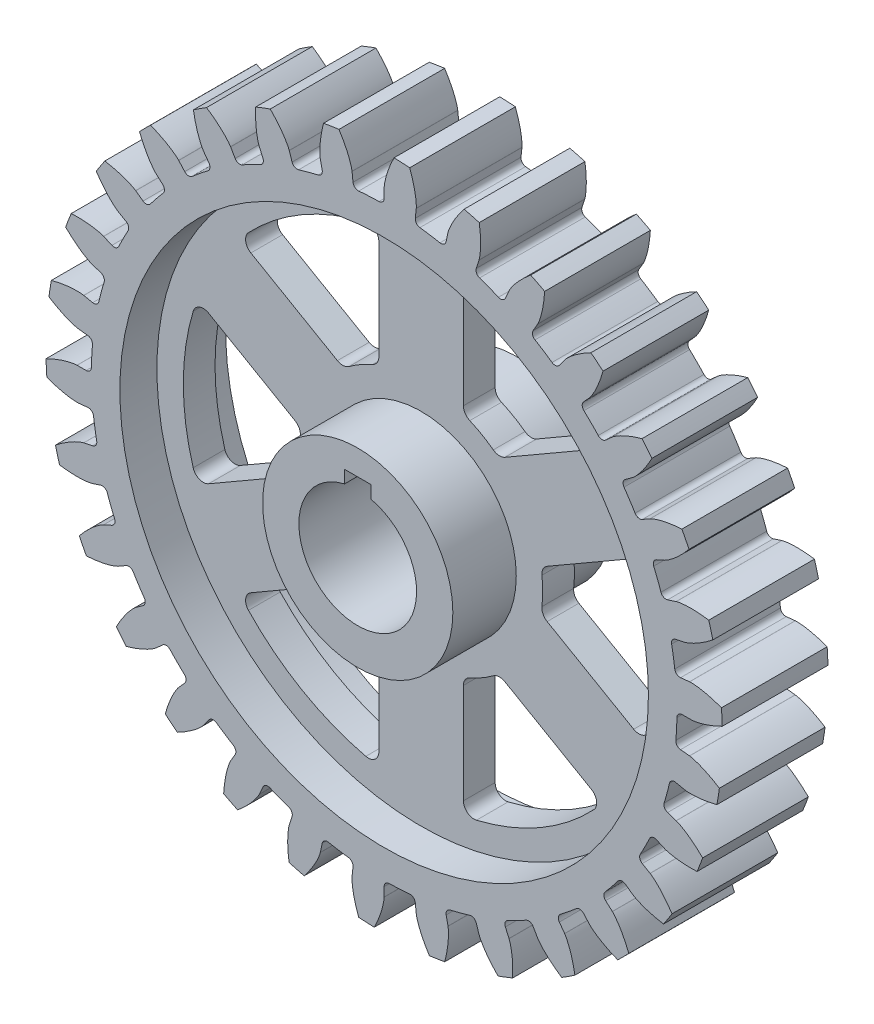
from build123d import *

# Parameters (mm, degrees)
BOSS_EXTRUDE1_START       = -12.7
BOSS_EXTRUDE1_DEPTH       = 25.4
FILLET5_R                 = 1.27
FILLET6_R                 = 1.27
CIRPATTERN2_COUNT         = 30
FILLET5_OF_CIRPATTERN2_R  = 1.27
FILLET6_OF_CIRPATTERN2_R  = 1.27
CUT_EXTRUDE2_DEPTH        = 20.05
CUT_EXTRUDE2_DEPTH_BACK   = 20.05
CUT_EXTRUDE3_DEPTH        = 20.05
FILLET7_R                 = 2.54
FILLET8_R                 = 2.54
FILLET9_R                 = 2.54
FILLET10_R                = 2.54
CIRPATTERN3_COUNT         = 6
FILLET7_OF_CIRPATTERN3_R  = 2.54
FILLET8_OF_CIRPATTERN3_R  = 2.54
FILLET9_OF_CIRPATTERN3_R  = 2.54
FILLET10_OF_CIRPATTERN3_R = 2.54


with BuildPart() as part:
    # Sketch1 → Revolve1 (revolve)
    with BuildSketch(Plane(origin=(0, 0, 0), x_dir=(0, 0, -1), z_dir=(1, 0, 0))):
        Polygon((-19.05, 0), (19.05, 0), (19.05, 22.86), (3.81, 22.86), (3.81, 63.5), (12.7, 63.5), (12.7, 70.358), (-12.7, 70.358), (-12.7, 63.5), (-3.81, 63.5), (-3.81, 22.86), (-19.05, 22.86), align=None)
    revolve(axis=Axis((0, 0, 20.955), (0, 0, -1)))

    # Sketch2 → Boss-Extrude1 (add)
    with BuildSketch(Plane.XY.offset(BOSS_EXTRUDE1_START)):
        with BuildLine():
            Line((73.787, 0), (70.358, 0))
            ThreePointArc((70.358, 0), (70.261576806, 3.682253209), (69.972571514, 7.354413619))
            Line((69.972571514, 7.354413619), (73.382787093, 7.712841719))
            add(Edge.make_bspline(
                [(73.382787093, 7.712841719), (73.43715987, 7.717395802), (73.589918341, 7.726601957), (73.879547725, 7.729925227), (74.35231969, 7.715277138), (74.954131213, 7.6672137), (75.72992196, 7.571305619), (76.639687317, 7.415196261), (77.633599645, 7.19844931), (78.70649498, 6.91461528), (79.695065382, 6.611264762), (80.410512864, 6.366046257), (80.860156706, 6.202224664), (81.04836389, 6.131974458)],
                knots=[0, 0, 0, 0, 0, 0.005376748, 0.015083688, 0.02853182, 0.046610139, 0.064854849, 0.092110525, 0.119476175, 0.146842495, 0.174208853, 0.194009379, 0.194009379, 0.194009379, 0.194009379, 0.194009379], degree=4))
            ThreePointArc((81.04836389, 6.131974458), (81.168608585, 4.253866523), (81.245338339, 2.373478068))
            add(Edge.make_bspline(
                [(73.787, 0), (73.841550948, 0.001154368), (73.994434897, 0.007966253), (74.282825037, 0.034935703), (74.751475967, 0.098921675), (75.344966706, 0.20962825), (76.106482465, 0.386103151), (76.994946161, 0.6364537), (77.960757507, 0.955905417), (78.998106674, 1.350332676), (79.949552821, 1.755355153), (80.635448694, 2.074014951), (81.06550532, 2.283939691), (81.245338339, 2.373478068)],
                knots=[0, 0, 0, 0, 0, 0.005376748, 0.015083688, 0.02853182, 0.046610139, 0.064854849, 0.092110525, 0.119476175, 0.146842495, 0.174208853, 0.194009379, 0.194009379, 0.194009379, 0.194009379, 0.194009379], degree=4))
        make_face()
    boss_extrude1 = extrude(amount=BOSS_EXTRUDE1_DEPTH)

    # Fillet5
    fillet5_edges = [part.edges().sort_by_distance(p)[0] for p in [
        (73.382787093, 7.712841719, 0),
        (69.972571514, 7.354413619, 0),
    ]]
    fillet(fillet5_edges, radius=FILLET5_R)

    # Fillet6
    fillet6_edges = [part.edges().sort_by_distance(p)[0] for p in [
        (70.358, 0, 0),
        (73.787, 0, 0),
    ]]
    fillet(fillet6_edges, radius=FILLET6_R)

    # CirPattern2: Boss-Extrude1 ×30 about axis
    cirpattern2_axis = Axis((0, 0, 20.955), (0, 0, -1))
    for i in range(1, CIRPATTERN2_COUNT):
        add(boss_extrude1.rotate(cirpattern2_axis, i * 360 / CIRPATTERN2_COUNT))

    # Fillet5 of CirPattern2
    fillet5_of_cirpattern2_edges = [part.edges().sort_by_distance(p)[0] for p in [
        (73.382787093, -7.712841719, 0),
        (69.972571514, -7.354413619, 0),
        (70.175607168, -22.801436964, 0),
        (66.914434373, -21.74181769, 0),
        (63.901416469, -36.8935, 0),
        (60.931815359, -35.179, 0),
        (54.834427237, -49.373140051, 0),
        (52.286183631, -47.078691202, 0),
        (43.370910411, -59.694936964, 0),
        (41.355394781, -56.92081769, 0),
        (30.011876683, -67.407778683, 0),
        (28.617176734, -64.275231309, 0),
        (15.34117993, -72.174577015, 0),
        (14.628250743, -68.820508892, 0),
        (0, -73.787, 0),
        (0, -70.358, 0),
        (-15.34117993, -72.174577015, 0),
        (-14.628250743, -68.820508892, 0),
        (-30.011876683, -67.407778683, 0),
        (-28.617176734, -64.275231309, 0),
        (-43.370910411, -59.694936964, 0),
        (-41.355394781, -56.92081769, 0),
        (-54.834427237, -49.373140051, 0),
        (-52.286183631, -47.078691202, 0),
        (-63.901416469, -36.8935, 0),
        (-60.931815359, -35.179, 0),
        (-70.175607168, -22.801436964, 0),
        (-66.914434373, -21.74181769, 0),
        (-73.382787093, -7.712841719, 0),
        (-69.972571514, -7.354413619, 0),
        (-73.382787093, 7.712841719, 0),
        (-69.972571514, 7.354413619, 0),
        (-70.175607168, 22.801436964, 0),
        (-66.914434373, 21.74181769, 0),
        (-63.901416469, 36.8935, 0),
        (-60.931815359, 35.179, 0),
        (-54.834427237, 49.373140051, 0),
        (-52.286183631, 47.078691202, 0),
        (-43.370910411, 59.694936964, 0),
        (-41.355394781, 56.92081769, 0),
        (-30.011876683, 67.407778683, 0),
        (-28.617176734, 64.275231309, 0),
        (-15.34117993, 72.174577015, 0),
        (-14.628250743, 68.820508892, 0),
        (0, 73.787, 0),
        (0, 70.358, 0),
        (15.34117993, 72.174577015, 0),
        (14.628250743, 68.820508892, 0),
        (30.011876683, 67.407778683, 0),
        (28.617176734, 64.275231309, 0),
        (43.370910411, 59.694936964, 0),
        (41.355394781, 56.92081769, 0),
        (54.834427237, 49.373140051, 0),
        (52.286183631, 47.078691202, 0),
        (63.901416469, 36.8935, 0),
        (60.931815359, 35.179, 0),
        (70.175607168, 22.801436964, 0),
        (66.914434373, 21.74181769, 0),
    ]]
    fillet(fillet5_of_cirpattern2_edges, radius=FILLET5_OF_CIRPATTERN2_R)

    # Fillet6 of CirPattern2
    fillet6_of_cirpattern2_edges = [part.edges().sort_by_distance(p)[0] for p in [
        (68.820508892, -14.628250743, 0),
        (72.174577015, -15.34117993, 0),
        (64.275231309, -28.617176734, 0),
        (67.407778683, -30.011876683, 0),
        (56.92081769, -41.355394781, 0),
        (59.694936964, -43.370910411, 0),
        (47.078691202, -52.286183631, 0),
        (49.373140051, -54.834427238, 0),
        (35.179, -60.931815359, 0),
        (36.8935, -63.901416469, 0),
        (21.74181769, -66.914434373, 0),
        (22.801436964, -70.175607168, 0),
        (7.354413619, -69.972571514, 0),
        (7.712841719, -73.382787094, 0),
        (-7.354413619, -69.972571514, 0),
        (-7.712841719, -73.382787094, 0),
        (-21.74181769, -66.914434373, 0),
        (-22.801436964, -70.175607168, 0),
        (-35.179, -60.931815359, 0),
        (-36.8935, -63.901416469, 0),
        (-47.078691202, -52.286183631, 0),
        (-49.373140051, -54.834427238, 0),
        (-56.92081769, -41.355394781, 0),
        (-59.694936964, -43.370910411, 0),
        (-64.275231309, -28.617176734, 0),
        (-67.407778683, -30.011876683, 0),
        (-68.820508892, -14.628250743, 0),
        (-72.174577015, -15.34117993, 0),
        (-70.358, 0, 0),
        (-73.787, 0, 0),
        (-68.820508892, 14.628250743, 0),
        (-72.174577015, 15.34117993, 0),
        (-64.275231309, 28.617176734, 0),
        (-67.407778683, 30.011876683, 0),
        (-56.92081769, 41.355394781, 0),
        (-59.694936964, 43.370910411, 0),
        (-47.078691202, 52.286183631, 0),
        (-49.373140051, 54.834427238, 0),
        (-35.179, 60.931815359, 0),
        (-36.8935, 63.901416469, 0),
        (-21.74181769, 66.914434373, 0),
        (-22.801436964, 70.175607168, 0),
        (-7.354413619, 69.972571514, 0),
        (-7.712841719, 73.382787094, 0),
        (7.354413619, 69.972571514, 0),
        (7.712841719, 73.382787094, 0),
        (21.74181769, 66.914434373, 0),
        (22.801436964, 70.175607168, 0),
        (35.179, 60.931815359, 0),
        (36.8935, 63.901416469, 0),
        (47.078691202, 52.286183631, 0),
        (49.373140051, 54.834427238, 0),
        (56.92081769, 41.355394781, 0),
        (59.694936964, 43.370910411, 0),
        (64.275231309, 28.617176734, 0),
        (67.407778683, 30.011876683, 0),
        (68.820508892, 14.628250743, 0),
        (72.174577015, 15.34117993, 0),
    ]]
    fillet(fillet6_of_cirpattern2_edges, radius=FILLET6_OF_CIRPATTERN2_R)

    # Sketch3 → Cut-Extrude2 (cut, two sides)
    with BuildSketch(Plane.XY) as cut_extrude2_sk:
        with BuildLine():
            Line((0, 16.829988415), (3.175, 16.829988415))
            Line((3.175, 16.829988415), (3.175, 13.781988415))
            ThreePointArc((3.175, 13.781988415), (0, -14.142978105), (-3.175, 13.781988415))
            Line((-3.175, 13.781988415), (-3.175, 16.829988415))
            Line((-3.175, 16.829988415), (0, 16.829988415))
        make_face()
    extrude(amount=CUT_EXTRUDE2_DEPTH, mode=Mode.SUBTRACT)
    extrude(cut_extrude2_sk.sketch, amount=-CUT_EXTRUDE2_DEPTH_BACK, mode=Mode.SUBTRACT)

    # Sketch4 → Cut-Extrude3 (cut, symmetric)
    with BuildSketch(Plane.XY):
        with BuildLine():
            Line((10.16, 45.343606692), (10.16, 32.643606692))
            Line((10.16, 32.643606692), (10.16, 27.386103466))
            ThreePointArc((10.16, 27.386103466), (14.605001395, 25.296604462), (18.637061312, 22.491869835))
            Line((18.637061312, 22.491869835), (21.428978037, 24.103783708))
            Line((21.428978037, 24.103783708), (36.826909717, 32.993783708))
            Line((36.826909717, 32.993783708), (43.624955343, 36.918637181))
            ThreePointArc((43.624955343, 36.918637181), (28.575, 49.493351826), (10.16, 56.239638157))
            Line((10.16, 56.239638157), (10.16, 45.343606692))
        make_face()
    cut_extrude3 = extrude(amount=CUT_EXTRUDE3_DEPTH, both=True, mode=Mode.SUBTRACT)

    # Fillet7
    fillet7_edges = [part.edges().sort_by_distance(p)[0] for p in [
        (10.16, 56.239638157, 0),
    ]]
    fillet(fillet7_edges, radius=FILLET7_R)

    # Fillet8
    fillet8_edges = [part.edges().sort_by_distance(p)[0] for p in [
        (10.16, 27.386103466, 0),
    ]]
    fillet(fillet8_edges, radius=FILLET8_R)

    # Fillet9
    fillet9_edges = [part.edges().sort_by_distance(p)[0] for p in [
        (18.637061312, 22.491869835, 0),
    ]]
    fillet(fillet9_edges, radius=FILLET9_R)

    # Fillet10
    fillet10_edges = [part.edges().sort_by_distance(p)[0] for p in [
        (43.624955343, 36.918637181, 0),
    ]]
    fillet(fillet10_edges, radius=FILLET10_R)

    # CirPattern3: Cut-Extrude3 ×6 about axis
    cirpattern3_axis = Axis((0, 0, 0), (0, 0, 1))
    for i in range(1, CIRPATTERN3_COUNT):
        add(cut_extrude3.rotate(cirpattern3_axis, i * 360 / CIRPATTERN3_COUNT), mode=Mode.SUBTRACT)

    # Fillet7 of CirPattern3
    fillet7_of_cirpattern3_edges = [part.edges().sort_by_distance(p)[0] for p in [
        (-43.624955343, 36.918637181, 0),
        (-53.784955343, -19.321000976, 0),
        (-10.16, -56.239638157, 0),
        (43.624955343, -36.918637181, 0),
        (53.784955343, 19.321000976, 0),
    ]]
    fillet(fillet7_of_cirpattern3_edges, radius=FILLET7_OF_CIRPATTERN3_R)

    # Fillet8 of CirPattern3
    fillet8_of_cirpattern3_edges = [part.edges().sort_by_distance(p)[0] for p in [
        (-18.637061312, 22.491869835, 0),
        (-28.797061312, -4.894233631, 0),
        (-10.16, -27.386103466, 0),
        (18.637061312, -22.491869835, 0),
        (28.797061312, 4.894233631, 0),
    ]]
    fillet(fillet8_of_cirpattern3_edges, radius=FILLET8_OF_CIRPATTERN3_R)

    # Fillet9 of CirPattern3
    fillet9_of_cirpattern3_edges = [part.edges().sort_by_distance(p)[0] for p in [
        (-10.16, 27.386103466, 0),
        (-28.797061312, 4.894233631, 0),
        (-18.637061312, -22.491869835, 0),
        (10.16, -27.386103466, 0),
        (28.797061312, -4.894233631, 0),
    ]]
    fillet(fillet9_of_cirpattern3_edges, radius=FILLET9_OF_CIRPATTERN3_R)

    # Fillet10 of CirPattern3
    fillet10_of_cirpattern3_edges = [part.edges().sort_by_distance(p)[0] for p in [
        (-10.16, 56.239638157, 0),
        (-53.784955343, 19.321000976, 0),
        (-43.624955343, -36.918637181, 0),
        (10.16, -56.239638157, 0),
        (53.784955343, -19.321000976, 0),
    ]]
    fillet(fillet10_of_cirpattern3_edges, radius=FILLET10_OF_CIRPATTERN3_R)


solid = part.part
